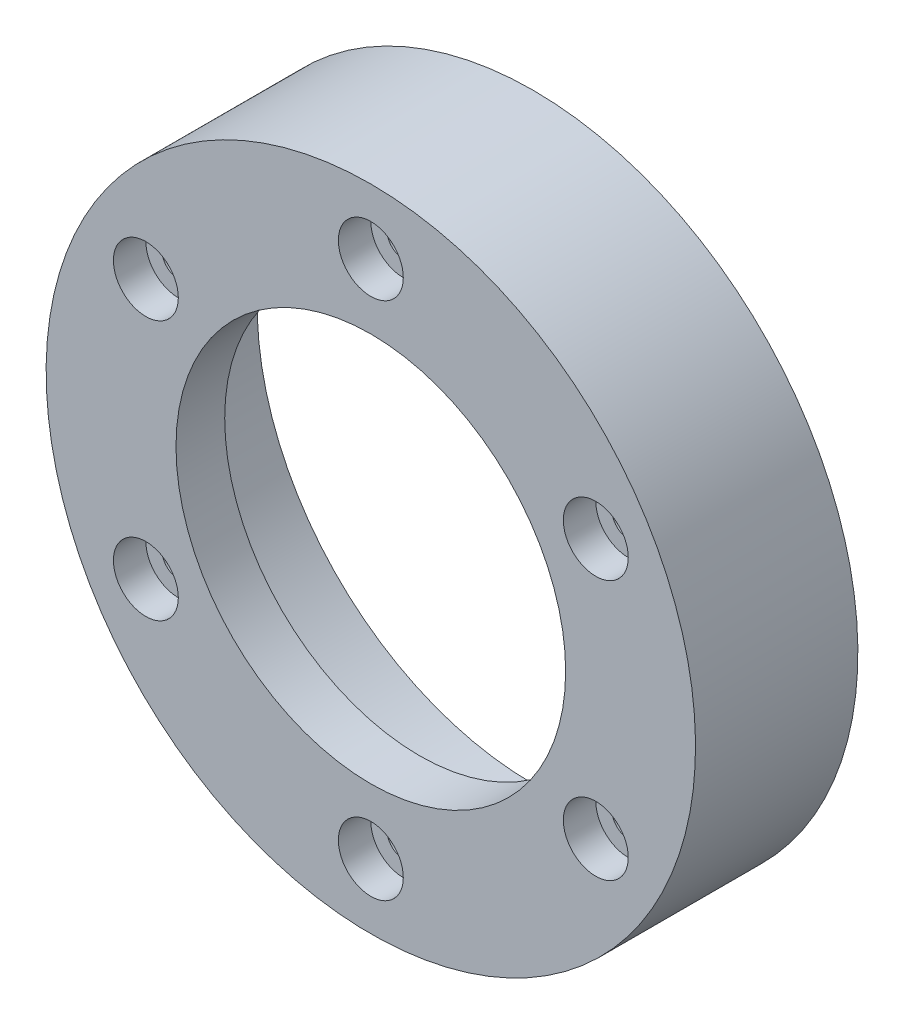
from build123d import *

# Parameters (mm, degrees)
CBORE_FOR_0_BINDING_HEAD_MACHINE_SCREW1_D           = 3.175
CBORE_FOR_0_BINDING_HEAD_MACHINE_SCREW1_CBORE_D     = 6.35
CBORE_FOR_0_BINDING_HEAD_MACHINE_SCREW1_CBORE_DEPTH = 3.175


with BuildPart() as part:
    # Sketch1 → Revolve1 (revolve)
    with BuildSketch(Plane(origin=(0, 0, 0), x_dir=(0, 0, -1), z_dir=(1, 0, 0))):
        Polygon((-7.9375, 31.75), (7.9375, 31.75), (7.9375, 26.9875), (-3.175, 26.9875), (-3.175, 19.05), (-7.9375, 19.05), align=None)
    revolve(axis=Axis((0, 0, -7.9375), (0, 0, 1)))

    # CBORE for #0 Binding Head Machine Screw1 (through all)
    with Locations(Plane.XY.offset(7.9375)):
        with Locations((0, 25.4), (21.997045256, 12.7), (21.997045256, -12.7), (0, -25.4), (-21.997045256, -12.7), (-21.997045256, 12.7)):
            CounterBoreHole(CBORE_FOR_0_BINDING_HEAD_MACHINE_SCREW1_D / 2, CBORE_FOR_0_BINDING_HEAD_MACHINE_SCREW1_CBORE_D / 2, CBORE_FOR_0_BINDING_HEAD_MACHINE_SCREW1_CBORE_DEPTH)


solid = part.part
